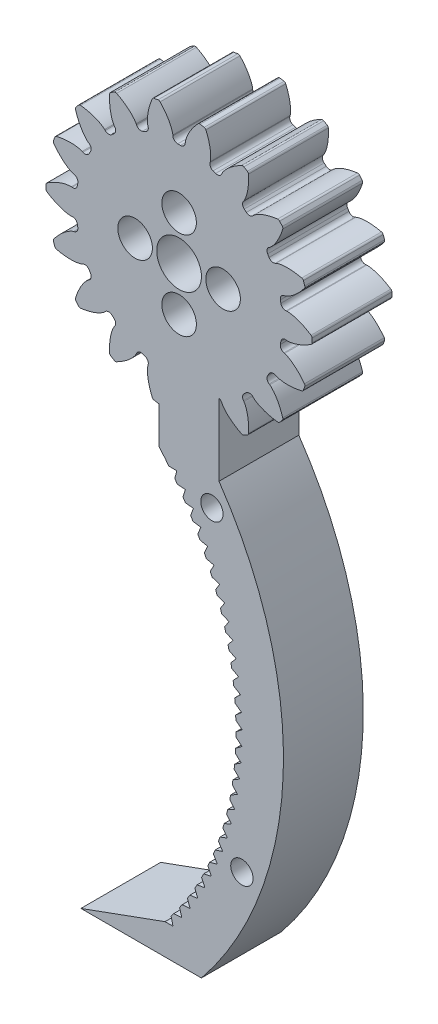
from build123d import *

# Parameters (mm, degrees)
SKETCH1_R                                 = 21.166666667
BOSS_EXTRUDE1_DEPTH                       = 12.7
CUT_EXTRUDE_DCLTBC_DEPTH                  = 13.7
FILLET_TIP_DCLTBC_R                       = 0.376401082
FILLET_ROOT_DCLTBC_R                      = 0.752802164
CIRPATTERN_DCLTBC_COUNT                   = 18
FILLET_TIP_DCLTBC_OF_CIRPATTERN_DCLTBC_R  = 0.376401082
FILLET_ROOT_DCLTBC_OF_CIRPATTERN_DCLTBC_R = 0.752802164
SKETCH4_R                                 = 3.556
CUT_EXTRUDE2_DEPTH                        = 13.7000001
SKETCH5_R                                 = 1
CUT_EXTRUDE3_DEPTH                        = 13.7000001
BOSS_EXTRUDE3_DEPTH                       = 12.7
SKETCH9_R                                 = 1.778
CUT_EXTRUDE4_DEPTH                        = 101.6
SKETCH10_R                                = 2.75
CUT_EXTRUDE5_DEPTH                        = 7.7
CUT_EXTRUDE6_DEPTH                        = 13.7000001
CIRPATTERN1_COUNT                         = 30
CIRPATTERN1_ANGLE                         = 75


with BuildPart() as part:
    # Sketch1 → Boss-Extrude1 (new body)
    with BuildSketch(Plane.XY):
        Circle(SKETCH1_R)
    extrude(amount=BOSS_EXTRUDE1_DEPTH)

    # DCLTBC → Cut-Extrude-DCLTBC (cut, through all)
    with BuildSketch(Plane.XY):
        with BuildLine():
            Line((-0.988599485, 17.23683661), (-0.939299003, 16.37725256))
            ThreePointArc((-0.939299003, 16.37725256), (0, 16.404166667), (0.939299003, 16.37725256))
            Line((0.939299003, 16.37725256), (0.988599485, 17.23683661))
            add(Edge.make_bspline(
                [(0.988599485, 17.23683661), (0.989063314, 17.24324115), (0.990661792, 17.261181979), (0.994858273, 17.295004515), (1.003369641, 17.350013815), (1.016655031, 17.419804647), (1.036619493, 17.509601098), (1.063718234, 17.614795353), (1.097234262, 17.729707804), (1.137709634, 17.85389969), (1.181621422, 17.977005275), (1.228695452, 18.099012466), (1.278527467, 18.219794849), (1.342341331, 18.365146152), (1.42364652, 18.538069209), (1.525589195, 18.738036686), (1.649316002, 18.962165854), (1.783980218, 19.187521629), (1.923498112, 19.406676656), (2.072405817, 19.624910262), (2.222105415, 19.833784741), (2.385586794, 20.047220122), (2.540566559, 20.242458208), (2.722891612, 20.457068476), (2.872582231, 20.629074977), (3.034353491, 20.803165616), (3.114136758, 20.887359483), (3.155350355, 20.930158669)],
                knots=[0, 0, 0, 0, 0, 0.005376749, 0.015083688, 0.02853182, 0.04661014, 0.064854849, 0.092110525, 0.119476176, 0.146842496, 0.174208854, 0.201574956, 0.228941013, 0.256307345, 0.307035032, 0.361767352, 0.416499661, 0.471231937, 0.525964282, 0.580696616, 0.635428982, 0.690161387, 0.744893688, 0.799626082, 0.854358408, 0.909090915, 0.909090915, 0.909090915, 0.909090915, 0.909090915], degree=4))
            ThreePointArc((3.155350355, 20.930158669), (0, 21.166666667), (-3.155350355, 20.930158669))
            add(Edge.make_bspline(
                [(-0.988599485, 17.23683661), (-0.989063314, 17.24324115), (-0.990661792, 17.261181979), (-0.994858273, 17.295004515), (-1.003369641, 17.350013815), (-1.016655031, 17.419804647), (-1.036619493, 17.509601098), (-1.063718234, 17.614795353), (-1.097234262, 17.729707804), (-1.137709634, 17.85389969), (-1.181621422, 17.977005275), (-1.228695452, 18.099012466), (-1.278527467, 18.219794849), (-1.342341331, 18.365146152), (-1.42364652, 18.538069209), (-1.525589195, 18.738036686), (-1.649316002, 18.962165854), (-1.783980218, 19.187521629), (-1.923498112, 19.406676656), (-2.072405817, 19.624910262), (-2.222105415, 19.833784741), (-2.385586794, 20.047220122), (-2.540566559, 20.242458208), (-2.722891612, 20.457068476), (-2.872582231, 20.629074977), (-3.034353491, 20.803165616), (-3.114136758, 20.887359483), (-3.155350355, 20.930158669)],
                knots=[0, 0, 0, 0, 0, 0.005376749, 0.015083688, 0.02853182, 0.04661014, 0.064854849, 0.092110525, 0.119476176, 0.146842496, 0.174208854, 0.201574956, 0.228941013, 0.256307345, 0.307035032, 0.361767352, 0.416499661, 0.471231937, 0.525964282, 0.580696616, 0.635428982, 0.690161387, 0.744893688, 0.799626082, 0.854358408, 0.909090915, 0.909090915, 0.909090915, 0.909090915, 0.909090915], degree=4))
        make_face()
    cut_extrude_dcltbc = extrude(amount=CUT_EXTRUDE_DCLTBC_DEPTH, mode=Mode.SUBTRACT)

    # Fillet-Tip-DCLTBC
    fillet_tip_dcltbc_edges = [part.edges().sort_by_distance(p)[0] for p in [
        (3.155350355, 20.930158669, 6.35),
        (-3.155350355, 20.930158669, 6.35),
    ]]
    fillet(fillet_tip_dcltbc_edges, radius=FILLET_TIP_DCLTBC_R)

    # Fillet-Root-DCLTBC
    fillet_root_dcltbc_edges = [part.edges().sort_by_distance(p)[0] for p in [
        (0.939299003, 16.37725256, 6.35),
        (-0.939299003, 16.37725256, 6.35),
    ]]
    fillet(fillet_root_dcltbc_edges, radius=FILLET_ROOT_DCLTBC_R)

    # CirPattern-DCLTBC: Cut-Extrude-DCLTBC ×18 about axis
    cirpattern_dcltbc_axis = Axis((0, 0, 12.7), (0, 0, 1))
    for i in range(1, CIRPATTERN_DCLTBC_COUNT):
        add(cut_extrude_dcltbc.rotate(cirpattern_dcltbc_axis, i * 360 / CIRPATTERN_DCLTBC_COUNT), mode=Mode.SUBTRACT)

    # Fillet-Tip-DCLTBC of CirPattern-DCLTBC
    fillet_tip_dcltbc_of_cirpattern_dcltbc_edges = [part.edges().sort_by_distance(p)[0] for p in [
        (-4.193476424, 20.747109034, 6.35),
        (-10.123595312, 18.588722273, 6.35),
        (-11.036508056, 18.061651854, 6.35),
        (-15.870785267, 14.00521163, 6.35),
        (-16.548373935, 13.1976929, 6.35),
        (-19.70372429, 7.73246577, 6.35),
        (-20.06426169, 6.741897404, 6.35),
        (-21.160103368, 0.527070418, 6.35),
        (-21.160103368, -0.527070418, 6.35),
        (-20.06426169, -6.741897404, 6.35),
        (-19.70372429, -7.73246577, 6.35),
        (-16.548373935, -13.1976929, 6.35),
        (-15.870785267, -14.00521163, 6.35),
        (-11.036508056, -18.061651854, 6.35),
        (-10.123595312, -18.588722273, 6.35),
        (-4.193476424, -20.747109034, 6.35),
        (-3.155350355, -20.930158669, 6.35),
        (3.155350355, -20.930158669, 6.35),
        (4.193476424, -20.747109034, 6.35),
        (10.123595312, -18.588722273, 6.35),
        (11.036508056, -18.061651854, 6.35),
        (15.870785267, -14.00521163, 6.35),
        (16.548373935, -13.1976929, 6.35),
        (19.70372429, -7.73246577, 6.35),
        (20.06426169, -6.741897404, 6.35),
        (21.160103368, -0.527070418, 6.35),
        (21.160103368, 0.527070418, 6.35),
        (20.06426169, 6.741897404, 6.35),
        (19.70372429, 7.73246577, 6.35),
        (16.548373935, 13.1976929, 6.35),
        (15.870785267, 14.00521163, 6.35),
        (11.036508056, 18.061651854, 6.35),
        (10.123595312, 18.588722273, 6.35),
        (4.193476424, 20.747109034, 6.35),
    ]]
    fillet(fillet_tip_dcltbc_of_cirpattern_dcltbc_edges, radius=FILLET_TIP_DCLTBC_OF_CIRPATTERN_DCLTBC_R)

    # Fillet-Root-DCLTBC of CirPattern-DCLTBC
    fillet_root_dcltbc_of_cirpattern_dcltbc_edges = [part.edges().sort_by_distance(p)[0] for p in [
        (-4.718697926, 15.710842559, 6.35),
        (-6.48400261, 15.0683242, 6.35),
        (-9.807550244, 13.149473078, 6.35),
        (-11.246639808, 11.941933556, 6.35),
        (-13.71346726, 9.002083078, 6.35),
        (-14.652766263, 7.375169482, 6.35),
        (-15.965337734, 3.768909003, 6.35),
        (-16.291552854, 1.918851122, 6.35),
        (-16.291552854, -1.918851122, 6.35),
        (-15.965337734, -3.768909003, 6.35),
        (-14.652766263, -7.375169482, 6.35),
        (-13.71346726, -9.002083078, 6.35),
        (-11.246639808, -11.941933556, 6.35),
        (-9.807550244, -13.149473078, 6.35),
        (-6.48400261, -15.0683242, 6.35),
        (-4.718697926, -15.710842559, 6.35),
        (-0.939299003, -16.37725256, 6.35),
        (0.939299003, -16.37725256, 6.35),
        (4.718697926, -15.710842559, 6.35),
        (6.48400261, -15.0683242, 6.35),
        (9.807550244, -13.149473078, 6.35),
        (11.246639808, -11.941933556, 6.35),
        (13.71346726, -9.002083078, 6.35),
        (14.652766263, -7.375169482, 6.35),
        (15.965337734, -3.768909003, 6.35),
        (16.291552854, -1.918851122, 6.35),
        (16.291552854, 1.918851122, 6.35),
        (15.965337734, 3.768909003, 6.35),
        (14.652766263, 7.375169482, 6.35),
        (13.71346726, 9.002083078, 6.35),
        (11.246639808, 11.941933556, 6.35),
        (9.807550244, 13.149473078, 6.35),
        (6.48400261, 15.0683242, 6.35),
        (4.718697926, 15.710842559, 6.35),
    ]]
    fillet(fillet_root_dcltbc_of_cirpattern_dcltbc_edges, radius=FILLET_ROOT_DCLTBC_OF_CIRPATTERN_DCLTBC_R)

    # Sketch4 → Cut-Extrude2 (cut, through all)
    with BuildSketch(Plane.XY.offset(12.7)):
        Circle(SKETCH4_R)
    extrude(amount=-CUT_EXTRUDE2_DEPTH, mode=Mode.SUBTRACT)

    # Sketch5 → Cut-Extrude3 (cut, through all)
    with BuildSketch(Plane.XY.offset(12.7)):
        with Locations((-7, 0)):
            Circle(SKETCH5_R)
        with Locations((0, 7)):
            Circle(SKETCH5_R)
        with Locations((7, 0)):
            Circle(SKETCH5_R)
        with Locations((0, -7)):
            Circle(SKETCH5_R)
    extrude(amount=-CUT_EXTRUDE3_DEPTH, mode=Mode.SUBTRACT)

    # Sketch7 → Boss-Extrude3 (add, through all)
    with BuildSketch(Plane.XY.offset(12.7)):
        with BuildLine():
            Line((6.35, -14.113720517), (6.35, -26.813720517))
            ThreePointArc((6.35, -26.813720517), (16.563553869, -62.204697552), (3.547653041, -96.663720517))
            Line((3.547653041, -96.663720517), (-15.629346959, -96.663720517))
            Line((-15.629346959, -96.663720517), (-2.2365023, -91.788432197))
            ThreePointArc((-2.2365023, -91.788432197), (9.041883703, -59.131392983), (-3.175, -26.813720517))
            Line((-3.175, -26.813720517), (-3.175, -14.113720517))
            Line((-3.175, -14.113720517), (6.35, -14.113720517))
        make_face()
    extrude(amount=-BOSS_EXTRUDE3_DEPTH)

    # Sketch9 → Cut-Extrude4 (cut)
    with BuildSketch(Plane.XY.offset(12.7)):
        with Locations((5.222816577, -31.033083261)):
            Circle(SKETCH9_R)
        with Locations((9.993601717, -78.846696124)):
            Circle(SKETCH9_R)
    extrude(amount=-CUT_EXTRUDE4_DEPTH, mode=Mode.SUBTRACT)

    # Sketch10 → Cut-Extrude5 (cut)
    with BuildSketch(Plane.XY.offset(12.7)):
        with Locations((-7, 0)):
            Circle(SKETCH10_R)
        with Locations((0, -7)):
            Circle(SKETCH10_R)
        with Locations((7, 0)):
            Circle(SKETCH10_R)
        with Locations((0, 7)):
            Circle(SKETCH10_R)
    extrude(amount=-CUT_EXTRUDE5_DEPTH, mode=Mode.SUBTRACT)

    # Sketch11 → Cut-Extrude6 (cut, through all)
    with BuildSketch(Plane.XY.offset(12.7)):
        with BuildLine():
            Line((-2.2365023, -91.788432197), (-0.9665023, -91.788432197))
            Line((-0.9665023, -91.788432197), (-1.271582988, -90.555620056))
            ThreePointArc((-1.271582988, -90.555620056), (-1.749293325, -91.175743408), (-2.2365023, -91.788432197))
        make_face()
    cut_extrude6 = extrude(amount=-CUT_EXTRUDE6_DEPTH, mode=Mode.SUBTRACT)

    # CirPattern1: Cut-Extrude6 ×30 about axis
    cirpattern1_axis = Axis((-41.752817912, -59.865073971, 0), (0, 0, 1))
    for i in range(1, CIRPATTERN1_COUNT):
        add(cut_extrude6.rotate(cirpattern1_axis, i * CIRPATTERN1_ANGLE / (CIRPATTERN1_COUNT - 1)), mode=Mode.SUBTRACT)


solid = part.part
